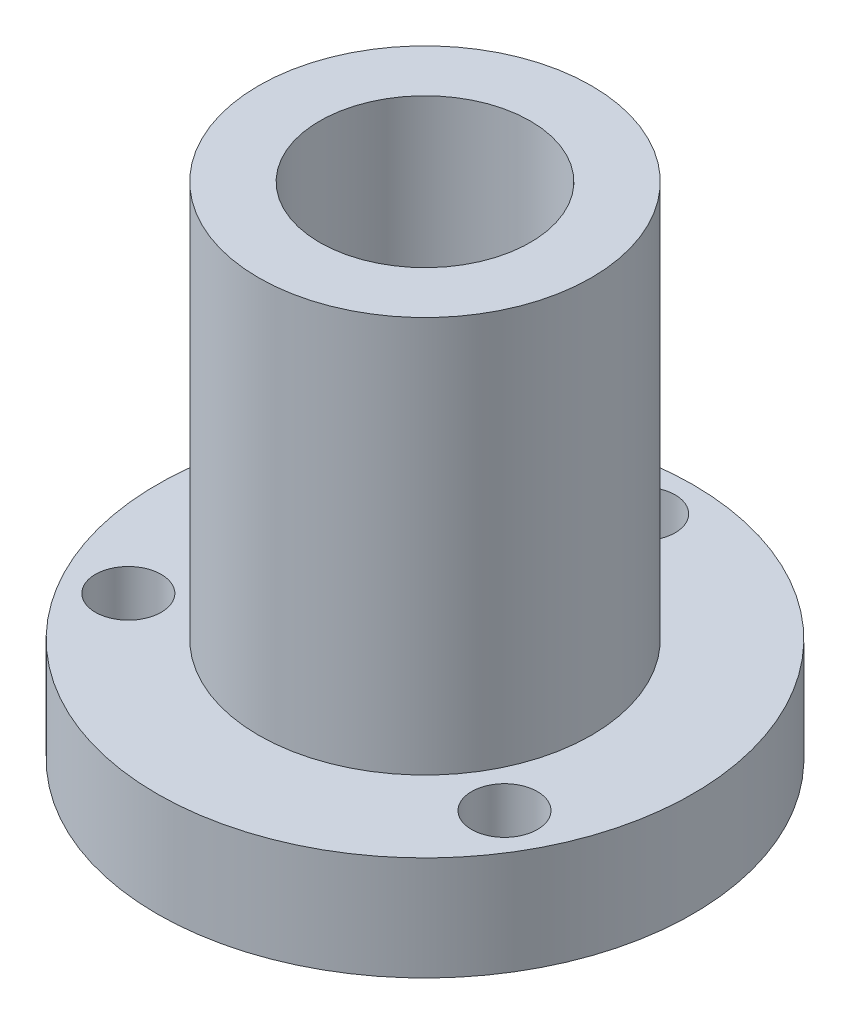
from build123d import *

# Parameters (mm, degrees)
SKETCH1_R                   = 10.175
SKETCH1_R_2                 = 4
BOSS_EXTRUDE1_DEPTH         = 3.95
SKETCH2_R                   = 6.32
SKETCH2_R_2                 = 4
BOSS_EXTRUDE2_DEPTH         = 15.05
TAP_DRILL_FOR_M3_TAP1_D     = 2.5
TAP_DRILL_FOR_M3_TAP1_DEPTH = 3.95


with BuildPart() as part:
    # Sketch1 → Boss-Extrude1 (new body)
    with BuildSketch(Plane(origin=(0, 0, 0), x_dir=(1, 0, 0), z_dir=(0, 1, 0))):
        Circle(SKETCH1_R)
        Circle(SKETCH1_R_2, mode=Mode.SUBTRACT)
    extrude(amount=BOSS_EXTRUDE1_DEPTH)

    # Sketch2 → Boss-Extrude2 (add)
    with BuildSketch(Plane(origin=(0, 3.95, 0), x_dir=(1, 0, 0), z_dir=(0, 1, 0))):
        Circle(SKETCH2_R)
        Circle(SKETCH2_R_2, mode=Mode.SUBTRACT)
    extrude(amount=BOSS_EXTRUDE2_DEPTH)

    # Tap Drill for M3 Tap1
    with Locations(Plane(origin=(-7.144709581, 0, 4.125), x_dir=(0, 0, -1), z_dir=(0, -1, 0))):
        with Locations((0, 0), (0, 14.289419162), (12.375, 7.144709581)):
            Hole(TAP_DRILL_FOR_M3_TAP1_D / 2, depth=TAP_DRILL_FOR_M3_TAP1_DEPTH)


solid = part.part
